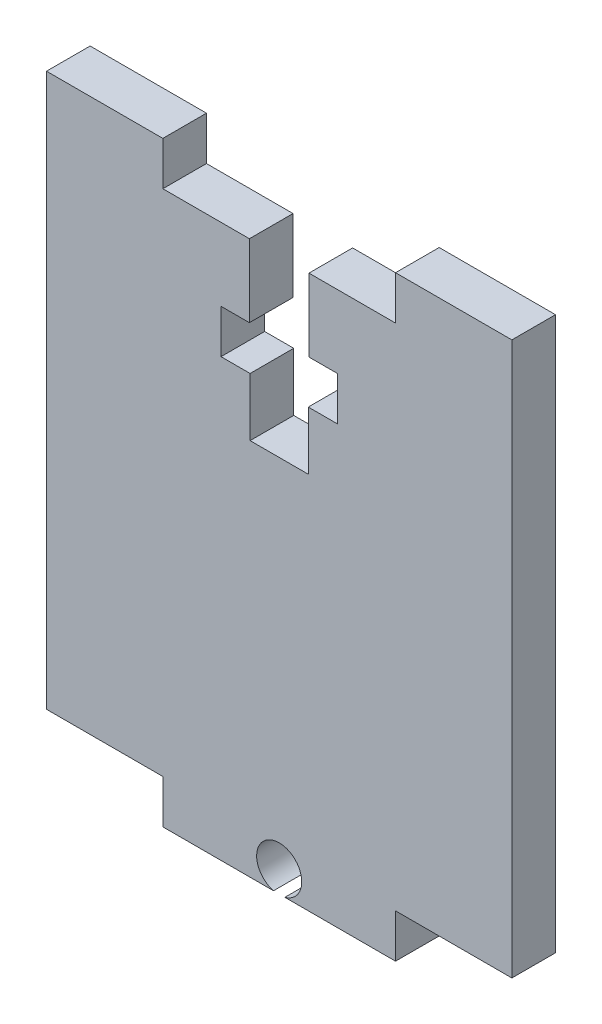
from build123d import *

# Parameters (mm, degrees)
EXTRUDE_1_DEPTH = 3


with BuildPart() as part:
    # 草图2 → 凸台-拉伸1 (new body)
    with BuildSketch(Plane.XY):
        with BuildLine():
            Line((2.047890023, 48.855305477), (8, 48.855305477))
            Line((8, 48.855305477), (8, 51.855305477))
            Line((8, 51.855305477), (16, 51.855305477))
            Line((16, 51.855305477), (16, 13.855305477))
            Line((16, 13.855305477), (8, 13.855305477))
            Line((8, 13.855305477), (8, 10.855305477))
            Line((8, 10.855305477), (0.390512484, 10.855305477))
            ThreePointArc((0.390512484, 10.855305477), (0, 13.905305477), (-0.390512484, 10.855305477))
            Line((-0.390512484, 10.855305477), (-8, 10.855305477))
            Line((-8, 10.855305477), (-8, 13.855305477))
            Line((-8, 13.855305477), (-16, 13.855305477))
            Line((-16, 13.855305477), (-16, 51.855305477))
            Line((-16, 51.855305477), (-8, 51.855305477))
            Line((-8, 51.855305477), (-8, 48.855305477))
            Line((-8, 48.855305477), (-2.047890023, 48.855305477))
            Line((-2.047890023, 48.855305477), (-2.047890023, 43.855305477))
            Line((-2.047890023, 43.855305477), (-4, 43.855305477))
            Line((-4, 43.855305477), (-4, 40.855305477))
            Line((-4, 40.855305477), (-2, 40.855305477))
            Line((-2, 40.855305477), (-2, 36.855305477))
            Line((-2, 36.855305477), (2, 36.855305477))
            Line((2, 36.855305477), (2, 40.855305477))
            Line((2, 40.855305477), (4, 40.855305477))
            Line((4, 40.855305477), (4, 43.855305477))
            Line((4, 43.855305477), (2.047890023, 43.855305477))
            Line((2.047890023, 43.855305477), (2.047890023, 48.855305477))
        make_face()
    extrude(amount=EXTRUDE_1_DEPTH)


solid = part.part
